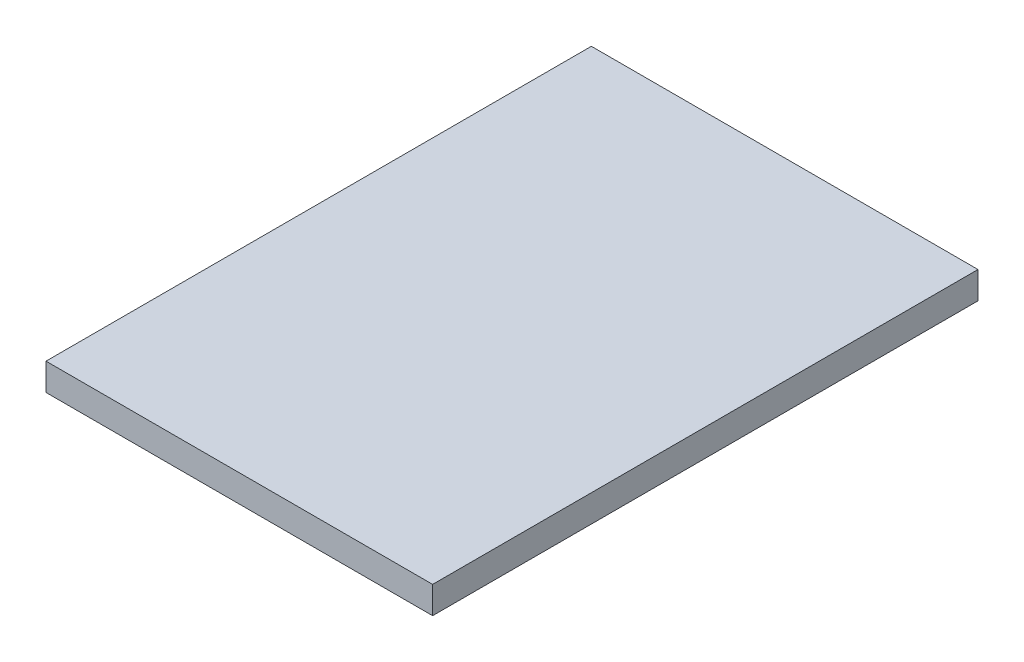
from build123d import *

# Parameters (mm, degrees)
SKETCH1_W           = 42.72
SKETCH1_H           = 60.26
BOSS_EXTRUDE1_DEPTH = 3


with BuildPart() as part:
    # Sketch1 → Boss-Extrude1 (new body)
    with BuildSketch(Plane(origin=(0, 0, 0), x_dir=(1, 0, 0), z_dir=(0, 1, 0))):
        with Locations((21.36, 30.13)):
            Rectangle(SKETCH1_W, SKETCH1_H)
    extrude(amount=BOSS_EXTRUDE1_DEPTH)


solid = part.part
